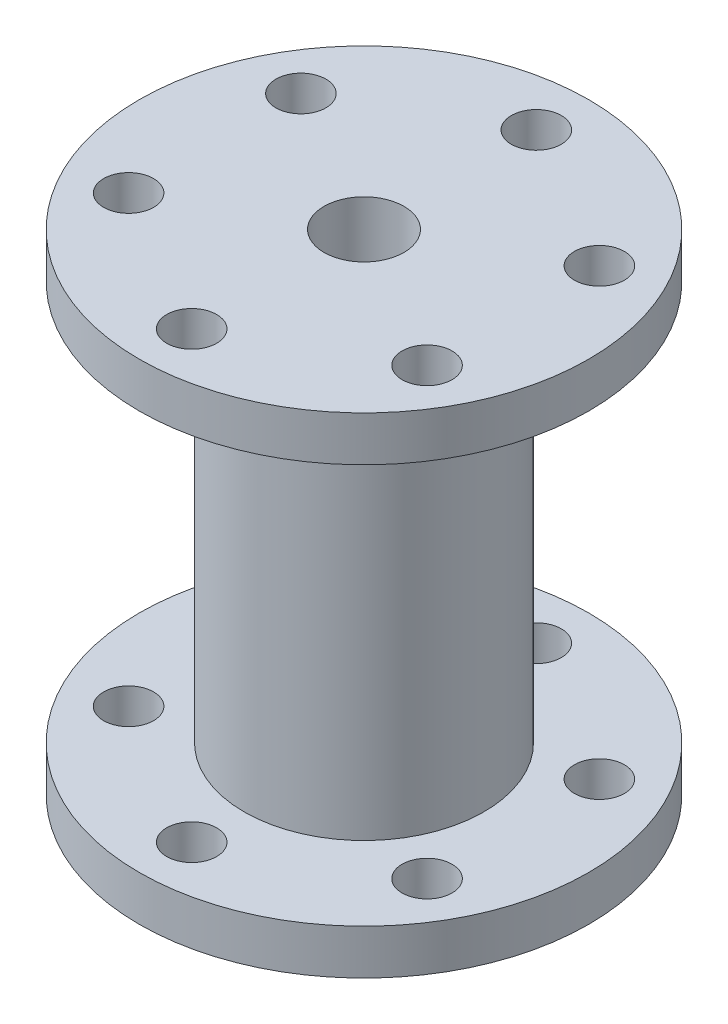
from build123d import *

# Parameters (mm, degrees)
SKETCH1_R           = 22.5
BOSS_EXTRUDE1_DEPTH = 4.5
SKETCH2_R           = 12
BOSS_EXTRUDE2_DEPTH = 40
SKETCH3_R           = 22.5
BOSS_EXTRUDE3_DEPTH = 4.5
SKETCH4_R           = 4
CUT_EXTRUDE1_DEPTH  = 60.5
SKETCH5_R           = 2.5
CUT_EXTRUDE2_DEPTH  = 60.5


with BuildPart() as part:
    # Sketch1 → Boss-Extrude1 (new body)
    with BuildSketch(Plane(origin=(0, 0, 0), x_dir=(1, 0, 0), z_dir=(0, 1, 0))):
        Circle(SKETCH1_R)
    extrude(amount=BOSS_EXTRUDE1_DEPTH)

    # Sketch2 → Boss-Extrude2 (add)
    with BuildSketch(Plane(origin=(0, 4.5, 0), x_dir=(1, 0, 0), z_dir=(0, 1, 0))):
        Circle(SKETCH2_R)
    extrude(amount=BOSS_EXTRUDE2_DEPTH)

    # Sketch3 → Boss-Extrude3 (add)
    with BuildSketch(Plane(origin=(0, 44.5, 0), x_dir=(1, 0, 0), z_dir=(0, 1, 0))):
        Circle(SKETCH3_R)
    extrude(amount=BOSS_EXTRUDE3_DEPTH)

    # Sketch4 → Cut-Extrude1 (cut)
    with BuildSketch(Plane.XZ):
        Circle(SKETCH4_R)
    extrude(amount=-CUT_EXTRUDE1_DEPTH, mode=Mode.SUBTRACT)

    # Sketch5 → Cut-Extrude2 (cut)
    with BuildSketch(Plane.XZ):
        with Locations((0, 17.25)):
            Circle(SKETCH5_R)
        with Locations((14.938938215, 8.625)):
            Circle(SKETCH5_R)
        with Locations((14.938938215, -8.625)):
            Circle(SKETCH5_R)
        with Locations((0, -17.25)):
            Circle(SKETCH5_R)
        with Locations((-14.938938215, -8.625)):
            Circle(SKETCH5_R)
        with Locations((-14.938938215, 8.625)):
            Circle(SKETCH5_R)
    extrude(amount=-CUT_EXTRUDE2_DEPTH, mode=Mode.SUBTRACT)


solid = part.part
